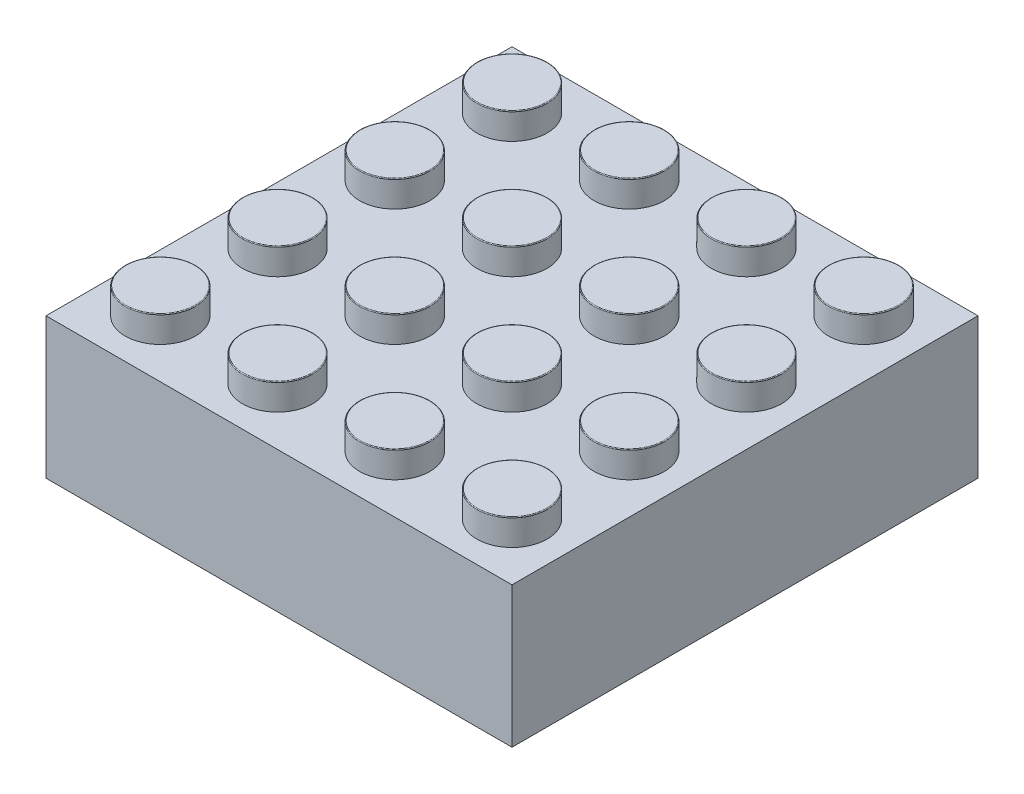
from build123d import *

# Parameters (mm, degrees)
SKETCH1_W                 = 31.8
SKETCH1_H                 = 31.8
BOSS_EXTRUDE1_DEPTH       = 9.6
SKETCH2_R                 = 2.4
BOSS_EXTRUDE2_DEPTH       = 1.8
LPATTERN1_COUNT           = 4
LPATTERN1_PITCH           = 8
LPATTERN2_COUNT           = 4
LPATTERN2_PITCH           = 8
LPATTERN2_COPY_1_SKETCH_R = 2.4
LPATTERN2_COPY_1_DEPTH    = 1.8
LPATTERN2_COPY_2_SKETCH_R = 2.4
LPATTERN2_COPY_2_DEPTH    = 1.8
LPATTERN2_COPY_3_SKETCH_R = 2.4
LPATTERN2_COPY_3_DEPTH    = 1.8
LPATTERN2_COPY_4_SKETCH_R = 2.4
LPATTERN2_COPY_4_DEPTH    = 1.8
LPATTERN2_COPY_5_SKETCH_R = 2.4
LPATTERN2_COPY_5_DEPTH    = 1.8
LPATTERN2_COPY_6_SKETCH_R = 2.4
LPATTERN2_COPY_6_DEPTH    = 1.8
LPATTERN2_COPY_7_SKETCH_R = 2.4
LPATTERN2_COPY_7_DEPTH    = 1.8
LPATTERN2_COPY_8_SKETCH_R = 2.4
LPATTERN2_COPY_8_DEPTH    = 1.8
LPATTERN2_COPY_9_SKETCH_R = 2.4
LPATTERN2_COPY_9_DEPTH    = 1.8
FILLET1_R                 = 0.05
SKETCH3_W                 = 29.4
SKETCH3_H                 = 29.4
CUT_EXTRUDE1_DEPTH        = 6.8
SKETCH4_R                 = 3.2125
BOSS_EXTRUDE3_DEPTH       = 6.8
SKETCH5_R                 = 2.25
CUT_EXTRUDE2_DEPTH        = 6.8
LPATTERN3_COUNT           = 3
LPATTERN3_PITCH           = 8
LPATTERN4_COUNT           = 3
LPATTERN4_PITCH           = 8
LPATTERN4_COPY_1_SKETCH_R = 3.2125
LPATTERN4_COPY_1_DEPTH    = 6.8
LPATTERN4_COPY_2_SKETCH_R = 3.2125
LPATTERN4_COPY_2_DEPTH    = 6.8
LPATTERN4_COPY_3_SKETCH_R = 3.2125
LPATTERN4_COPY_3_DEPTH    = 6.8
LPATTERN4_COPY_4_SKETCH_R = 3.2125
LPATTERN4_COPY_4_DEPTH    = 6.8
LPATTERN4_COPY_5_SKETCH_R = 2.25
LPATTERN4_COPY_5_DEPTH    = 6.8
LPATTERN4_COPY_6_SKETCH_R = 2.25
LPATTERN4_COPY_6_DEPTH    = 6.8
LPATTERN4_COPY_7_SKETCH_R = 2.25
LPATTERN4_COPY_7_DEPTH    = 6.8
LPATTERN4_COPY_8_SKETCH_R = 2.25
LPATTERN4_COPY_8_DEPTH    = 6.8
SKETCH6_W                 = 0.3
SKETCH6_H                 = 0.6
BOSS_EXTRUDE4_DEPTH       = 6.8
CIRPATTERN1_COUNT         = 4


with BuildPart() as part:
    # Sketch1 → Boss-Extrude1 (new body)
    with BuildSketch(Plane(origin=(0, 0, 0), x_dir=(1, 0, 0), z_dir=(0, 1, 0))):
        Rectangle(SKETCH1_W, SKETCH1_H)
    extrude(amount=BOSS_EXTRUDE1_DEPTH)

    # Sketch2 → Boss-Extrude2 (add)
    with BuildSketch(Plane(origin=(0, 9.6, 0), x_dir=(1, 0, 0), z_dir=(0, 1, 0))):
        with Locations((-12, -12)):
            Circle(SKETCH2_R)
    boss_extrude2 = extrude(amount=BOSS_EXTRUDE2_DEPTH)

    # LPattern1: Boss-Extrude2 ×4
    with Locations(*[(0, 0, -i * LPATTERN1_PITCH) for i in range(1, LPATTERN1_COUNT)]):
        add(boss_extrude2)

    # LPattern2: Boss-Extrude2 ×4
    with Locations(*[(i * LPATTERN2_PITCH, 0, 0) for i in range(1, LPATTERN2_COUNT)]):
        add(boss_extrude2)

    # LPattern2 copy 1 sketch → LPattern2 copy 1 (add)
    with BuildSketch(Plane(origin=(8, 9.6, -8), x_dir=(1, 0, 0), z_dir=(0, 1, 0))):
        with Locations((-12, -12)):
            Circle(LPATTERN2_COPY_1_SKETCH_R)
    extrude(amount=LPATTERN2_COPY_1_DEPTH)

    # LPattern2 copy 2 sketch → LPattern2 copy 2 (add)
    with BuildSketch(Plane(origin=(16, 9.6, -8), x_dir=(1, 0, 0), z_dir=(0, 1, 0))):
        with Locations((-12, -12)):
            Circle(LPATTERN2_COPY_2_SKETCH_R)
    extrude(amount=LPATTERN2_COPY_2_DEPTH)

    # LPattern2 copy 3 sketch → LPattern2 copy 3 (add)
    with BuildSketch(Plane(origin=(24, 9.6, -8), x_dir=(1, 0, 0), z_dir=(0, 1, 0))):
        with Locations((-12, -12)):
            Circle(LPATTERN2_COPY_3_SKETCH_R)
    extrude(amount=LPATTERN2_COPY_3_DEPTH)

    # LPattern2 copy 4 sketch → LPattern2 copy 4 (add)
    with BuildSketch(Plane(origin=(8, 9.6, -16), x_dir=(1, 0, 0), z_dir=(0, 1, 0))):
        with Locations((-12, -12)):
            Circle(LPATTERN2_COPY_4_SKETCH_R)
    extrude(amount=LPATTERN2_COPY_4_DEPTH)

    # LPattern2 copy 5 sketch → LPattern2 copy 5 (add)
    with BuildSketch(Plane(origin=(16, 9.6, -16), x_dir=(1, 0, 0), z_dir=(0, 1, 0))):
        with Locations((-12, -12)):
            Circle(LPATTERN2_COPY_5_SKETCH_R)
    extrude(amount=LPATTERN2_COPY_5_DEPTH)

    # LPattern2 copy 6 sketch → LPattern2 copy 6 (add)
    with BuildSketch(Plane(origin=(24, 9.6, -16), x_dir=(1, 0, 0), z_dir=(0, 1, 0))):
        with Locations((-12, -12)):
            Circle(LPATTERN2_COPY_6_SKETCH_R)
    extrude(amount=LPATTERN2_COPY_6_DEPTH)

    # LPattern2 copy 7 sketch → LPattern2 copy 7 (add)
    with BuildSketch(Plane(origin=(8, 9.6, -24), x_dir=(1, 0, 0), z_dir=(0, 1, 0))):
        with Locations((-12, -12)):
            Circle(LPATTERN2_COPY_7_SKETCH_R)
    extrude(amount=LPATTERN2_COPY_7_DEPTH)

    # LPattern2 copy 8 sketch → LPattern2 copy 8 (add)
    with BuildSketch(Plane(origin=(16, 9.6, -24), x_dir=(1, 0, 0), z_dir=(0, 1, 0))):
        with Locations((-12, -12)):
            Circle(LPATTERN2_COPY_8_SKETCH_R)
    extrude(amount=LPATTERN2_COPY_8_DEPTH)

    # LPattern2 copy 9 sketch → LPattern2 copy 9 (add)
    with BuildSketch(Plane(origin=(24, 9.6, -24), x_dir=(1, 0, 0), z_dir=(0, 1, 0))):
        with Locations((-12, -12)):
            Circle(LPATTERN2_COPY_9_SKETCH_R)
    extrude(amount=LPATTERN2_COPY_9_DEPTH)

    # Fillet1
    fillet1_edges = [part.edges().sort_by_distance(p)[0] for p in [
        (-14.4, 11.4, 12),
        (-14.4, 11.4, 4),
        (-14.4, 11.4, -4),
        (-14.4, 11.4, -12),
        (-6.4, 11.4, 4),
        (1.6, 11.4, 4),
        (9.6, 11.4, 4),
        (-6.4, 11.4, 12),
        (1.6, 11.4, 12),
        (9.6, 11.4, 12),
        (-6.4, 11.4, -12),
        (1.6, 11.4, -12),
        (9.6, 11.4, -12),
        (-6.4, 11.4, -4),
        (1.6, 11.4, -4),
        (9.6, 11.4, -4),
    ]]
    fillet(fillet1_edges, radius=FILLET1_R)

    # Sketch3 → Cut-Extrude1 (cut)
    with BuildSketch(Plane(origin=(0, 0, 0), x_dir=(-1, 0, 0), z_dir=(0, -1, 0))):
        Rectangle(SKETCH3_W, SKETCH3_H)
    extrude(amount=-CUT_EXTRUDE1_DEPTH, mode=Mode.SUBTRACT)

    # Sketch4 → Boss-Extrude3 (add)
    with BuildSketch(Plane(origin=(0, 6.8, 0), x_dir=(-1, 0, 0), z_dir=(0, -1, 0))):
        with Locations((-8, 8)):
            Circle(SKETCH4_R)
    boss_extrude3 = extrude(amount=BOSS_EXTRUDE3_DEPTH)

    # Sketch5 → Cut-Extrude2 (cut)
    with BuildSketch(Plane(origin=(0, 0, 0), x_dir=(-1, 0, 0), z_dir=(0, -1, 0))):
        with Locations((-8, 8)):
            Circle(SKETCH5_R)
    cut_extrude2 = extrude(amount=-CUT_EXTRUDE2_DEPTH, mode=Mode.SUBTRACT)

    # LPattern3: Boss-Extrude3, Cut-Extrude2 ×3
    with Locations(*[(-i * LPATTERN3_PITCH, 0, 0) for i in range(1, LPATTERN3_COUNT)]):
        add(boss_extrude3)
        add(cut_extrude2, mode=Mode.SUBTRACT)

    # LPattern4: Boss-Extrude3, Cut-Extrude2 ×3
    with Locations(*[(0, 0, i * LPATTERN4_PITCH) for i in range(1, LPATTERN4_COUNT)]):
        add(boss_extrude3)
        add(cut_extrude2, mode=Mode.SUBTRACT)

    # LPattern4 copy 1 sketch → LPattern4 copy 1 (add)
    with BuildSketch(Plane(origin=(-8, 6.8, 8), x_dir=(-1, 0, 0), z_dir=(0, -1, 0))):
        with Locations((-8, 8)):
            Circle(LPATTERN4_COPY_1_SKETCH_R)
    extrude(amount=LPATTERN4_COPY_1_DEPTH)

    # LPattern4 copy 2 sketch → LPattern4 copy 2 (add)
    with BuildSketch(Plane(origin=(-8, 6.8, 16), x_dir=(-1, 0, 0), z_dir=(0, -1, 0))):
        with Locations((-8, 8)):
            Circle(LPATTERN4_COPY_2_SKETCH_R)
    extrude(amount=LPATTERN4_COPY_2_DEPTH)

    # LPattern4 copy 3 sketch → LPattern4 copy 3 (add)
    with BuildSketch(Plane(origin=(-16, 6.8, 8), x_dir=(-1, 0, 0), z_dir=(0, -1, 0))):
        with Locations((-8, 8)):
            Circle(LPATTERN4_COPY_3_SKETCH_R)
    extrude(amount=LPATTERN4_COPY_3_DEPTH)

    # LPattern4 copy 4 sketch → LPattern4 copy 4 (add)
    with BuildSketch(Plane(origin=(-16, 6.8, 16), x_dir=(-1, 0, 0), z_dir=(0, -1, 0))):
        with Locations((-8, 8)):
            Circle(LPATTERN4_COPY_4_SKETCH_R)
    extrude(amount=LPATTERN4_COPY_4_DEPTH)

    # LPattern4 copy 5 sketch → LPattern4 copy 5 (cut)
    with BuildSketch(Plane(origin=(-8, 0, 8), x_dir=(-1, 0, 0), z_dir=(0, -1, 0))):
        with Locations((-8, 8)):
            Circle(LPATTERN4_COPY_5_SKETCH_R)
    extrude(amount=-LPATTERN4_COPY_5_DEPTH, mode=Mode.SUBTRACT)

    # LPattern4 copy 6 sketch → LPattern4 copy 6 (cut)
    with BuildSketch(Plane(origin=(-8, 0, 16), x_dir=(-1, 0, 0), z_dir=(0, -1, 0))):
        with Locations((-8, 8)):
            Circle(LPATTERN4_COPY_6_SKETCH_R)
    extrude(amount=-LPATTERN4_COPY_6_DEPTH, mode=Mode.SUBTRACT)

    # LPattern4 copy 7 sketch → LPattern4 copy 7 (cut)
    with BuildSketch(Plane(origin=(-16, 0, 8), x_dir=(-1, 0, 0), z_dir=(0, -1, 0))):
        with Locations((-8, 8)):
            Circle(LPATTERN4_COPY_7_SKETCH_R)
    extrude(amount=-LPATTERN4_COPY_7_DEPTH, mode=Mode.SUBTRACT)

    # LPattern4 copy 8 sketch → LPattern4 copy 8 (cut)
    with BuildSketch(Plane(origin=(-16, 0, 16), x_dir=(-1, 0, 0), z_dir=(0, -1, 0))):
        with Locations((-8, 8)):
            Circle(LPATTERN4_COPY_8_SKETCH_R)
    extrude(amount=-LPATTERN4_COPY_8_DEPTH, mode=Mode.SUBTRACT)

    # Sketch6 → Boss-Extrude4 (add)
    with BuildSketch(Plane(origin=(0, 0, 0), x_dir=(-1, 0, 0), z_dir=(0, -1, 0))):
        with Locations((14.55, -12)):
            Rectangle(SKETCH6_W, SKETCH6_H)
        with Locations((14.55, -4)):
            Rectangle(SKETCH6_W, SKETCH6_H)
        with Locations((14.55, 4)):
            Rectangle(SKETCH6_W, SKETCH6_H)
        with Locations((14.55, 12)):
            Rectangle(SKETCH6_W, SKETCH6_H)
    boss_extrude4 = extrude(amount=-BOSS_EXTRUDE4_DEPTH)

    # CirPattern1: Boss-Extrude4 ×4 about axis
    cirpattern1_axis = Axis((0, 0, 0), (0, 1, 0))
    for i in range(1, CIRPATTERN1_COUNT):
        add(boss_extrude4.rotate(cirpattern1_axis, i * 360 / CIRPATTERN1_COUNT))


solid = part.part
